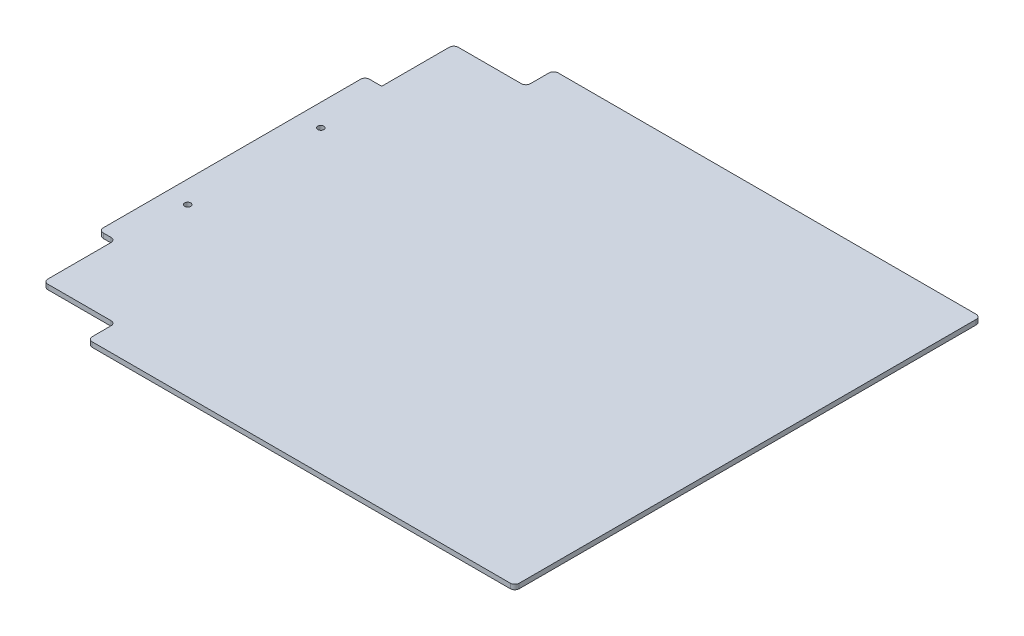
from build123d import *

# Parameters (mm, degrees)
SKETCH1_W           = 304.8
SKETCH1_H           = 304.8
BOSS_EXTRUDE1_DEPTH = 2.778125
SKETCH2_W           = 304.8
SKETCH2_H           = 19.05
CUT_EXTRUDE1_DEPTH  = 3.778125
CUT_EXTRUDE2_DEPTH  = 3.778125
SKETCH4_R           = 1.7526
CUT_EXTRUDE3_DEPTH  = 3.778125
SKETCH5_W           = 9.525
SKETCH5_H           = 266.7
CUT_EXTRUDE4_DEPTH  = 3.778125
FILLET1_R           = 2.54


with BuildPart() as part:
    # Sketch1 → Boss-Extrude1 (new body)
    with BuildSketch(Plane(origin=(0, 0, 0), x_dir=(1, 0, 0), z_dir=(0, 1, 0))):
        with Locations((152.4, 152.4)):
            Rectangle(SKETCH1_W, SKETCH1_H)
    extrude(amount=BOSS_EXTRUDE1_DEPTH)

    # Sketch2 → Cut-Extrude1 (cut, through all)
    with BuildSketch(Plane(origin=(0, 2.778125, 0), x_dir=(1, 0, 0), z_dir=(0, 1, 0))):
        with Locations((152.4, 9.525)):
            Rectangle(SKETCH2_W, SKETCH2_H)
        with Locations((152.4, 295.275)):
            Rectangle(SKETCH2_W, SKETCH2_H)
    extrude(amount=-CUT_EXTRUDE1_DEPTH, mode=Mode.SUBTRACT)

    # Sketch3 → Cut-Extrude2 (cut, through all)
    with BuildSketch(Plane(origin=(0, 2.778125, 0), x_dir=(1, 0, 0), z_dir=(0, 1, 0))):
        Polygon((50.8, 285.75), (0, 285.75), (0, 228.6), (9.525, 228.6), (9.525, 269.875), (50.8, 269.875), align=None)
        Polygon((0, 19.05), (0, 76.2), (9.525, 76.2), (9.525, 34.925), (50.8, 34.925), (50.8, 19.05), align=None)
    extrude(amount=-CUT_EXTRUDE2_DEPTH, mode=Mode.SUBTRACT)

    # Sketch4 → Cut-Extrude3 (cut, through all)
    with BuildSketch(Plane(origin=(0, 2.778125, 0), x_dir=(1, 0, 0), z_dir=(0, 1, 0))):
        with Locations((12.7, 190.5762)):
            Circle(SKETCH4_R)
        with Locations((12.7, 114.3762)):
            Circle(SKETCH4_R)
    extrude(amount=-CUT_EXTRUDE3_DEPTH, mode=Mode.SUBTRACT)

    # Sketch5 → Cut-Extrude4 (cut, through all)
    with BuildSketch(Plane(origin=(0, 2.778125, 0), x_dir=(1, 0, 0), z_dir=(0, 1, 0))):
        with Locations((300.0375, 152.4)):
            Rectangle(SKETCH5_W, SKETCH5_H)
    extrude(amount=-CUT_EXTRUDE4_DEPTH, mode=Mode.SUBTRACT)

    # Fillet1
    fillet1_edges = [part.edges().sort_by_distance(p)[0] for p in [
        (295.275, 1.3890625, -19.05),
        (295.275, 1.3890625, -285.75),
        (50.8, 1.3890625, -285.75),
        (50.8, 1.3890625, -269.875),
        (9.525, 1.3890625, -269.875),
        (0, 1.3890625, -228.6),
        (50.8, 1.3890625, -19.05),
        (0, 1.3890625, -76.2),
        (9.525, 1.3890625, -76.2),
        (9.525, 1.3890625, -34.925),
        (50.8, 1.3890625, -34.925),
    ]]
    fillet(fillet1_edges, radius=FILLET1_R)


solid = part.part
